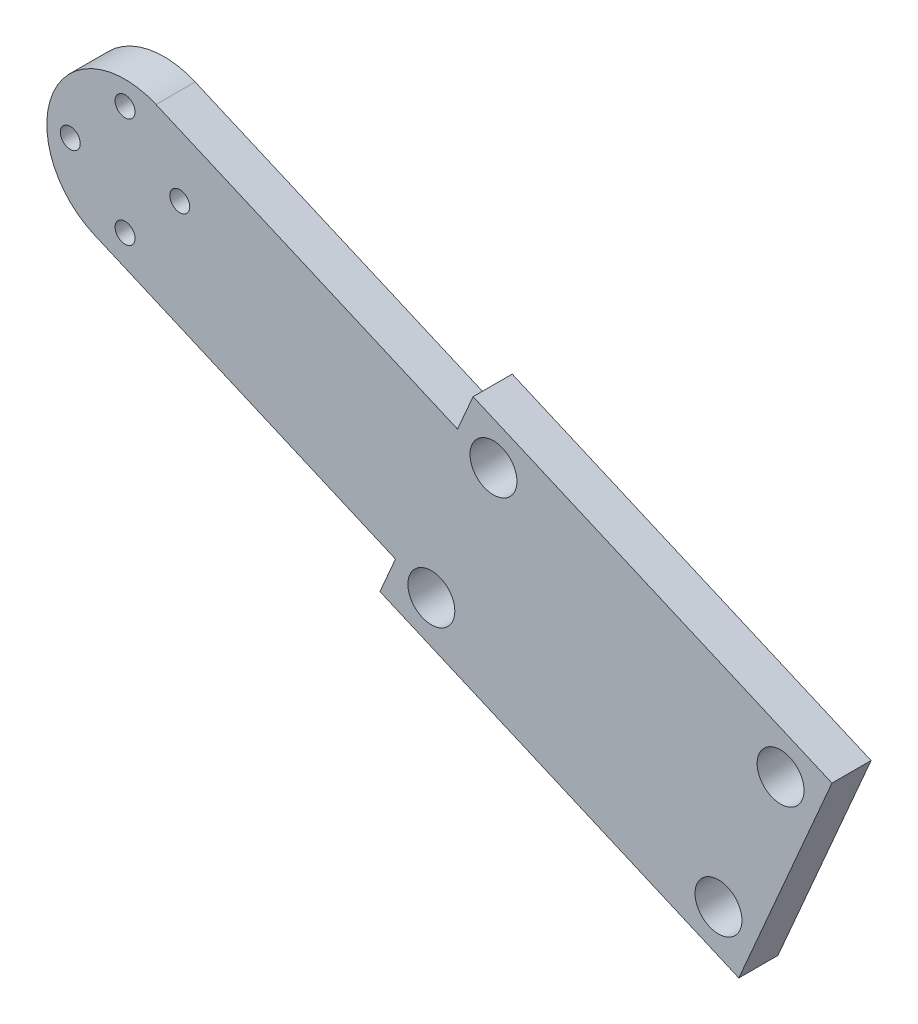
from build123d import *

# Parameters (mm, degrees)
ESQUISSE2_R        = 1.275
ESQUISSE2_R_2      = 3
BOSS_EXTRU_1_DEPTH = 5


with BuildPart() as part:
    # Esquisse2 → Boss.-Extru.1 (new body)
    with BuildSketch(Plane.XY):
        with BuildLine():
            Line((42.518708235, -7.493960905), (3.969600002, 9.178359103))
            ThreePointArc((3.969600002, 9.178359103), (-9.178359103, 3.969600002), (-3.969600002, -9.178359103))
            Line((-3.969600002, -9.178359103), (34.579508231, -25.850679111))
            Line((34.579508231, -25.850679111), (32.59470823, -30.439858662))
            Line((32.59470823, -30.439858662), (78.486503746, -50.287858671))
            Line((78.486503746, -50.287858671), (90.395303751, -22.752781362))
            Line((90.395303751, -22.752781362), (44.503508236, -2.904781353))
            Line((44.503508236, -2.904781353), (42.518708235, -7.493960905))
        make_face()
        with Locations((7, 0)):
            Circle(ESQUISSE2_R, mode=Mode.SUBTRACT)
        with Locations((0, 7)):
            Circle(ESQUISSE2_R, mode=Mode.SUBTRACT)
        with Locations((-7, 0)):
            Circle(ESQUISSE2_R, mode=Mode.SUBTRACT)
        with Locations((0, -7)):
            Circle(ESQUISSE2_R, mode=Mode.SUBTRACT)
        with Locations((75.882124195, -43.713879119)):
            Circle(ESQUISSE2_R_2, mode=Mode.SUBTRACT)
        with Locations((83.821324199, -25.357160913)):
            Circle(ESQUISSE2_R_2, mode=Mode.SUBTRACT)
        with Locations((47.107887786, -9.478760905)):
            Circle(ESQUISSE2_R_2, mode=Mode.SUBTRACT)
        with Locations((39.168687783, -27.835479112)):
            Circle(ESQUISSE2_R_2, mode=Mode.SUBTRACT)
    extrude(amount=BOSS_EXTRU_1_DEPTH)


solid = part.part
